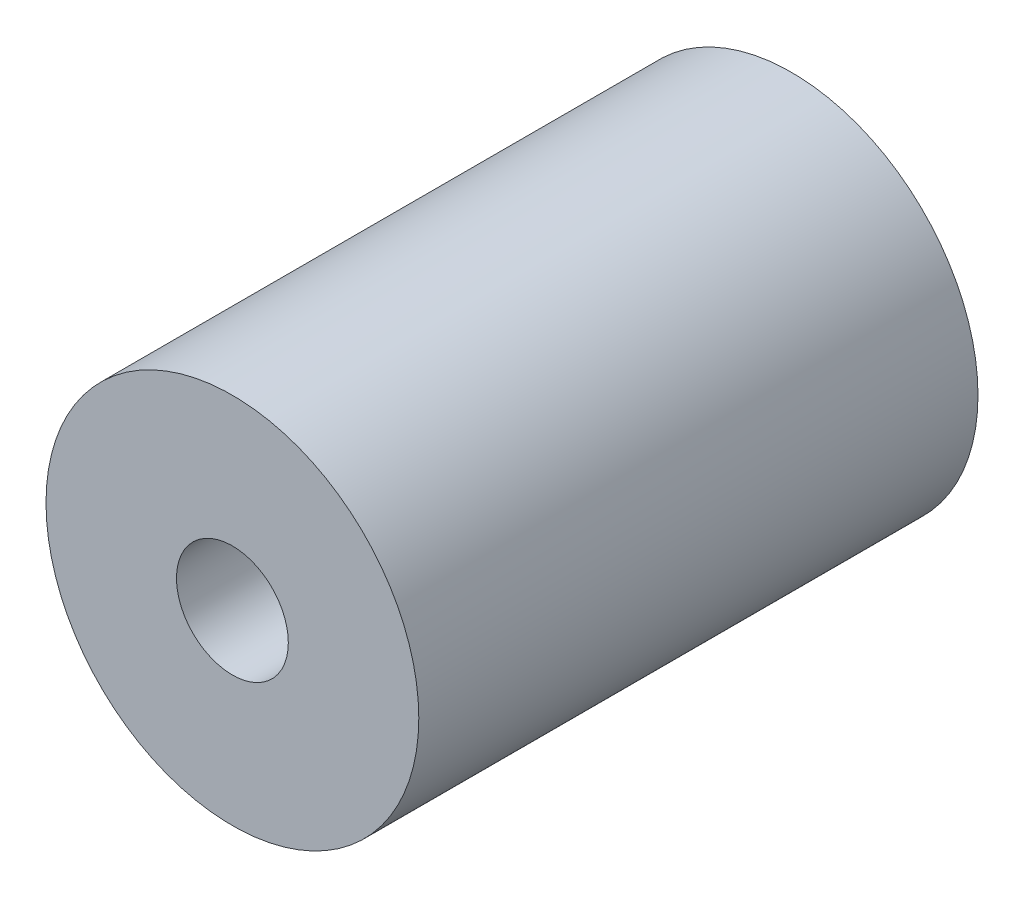
from build123d import *

# Parameters (mm, degrees)
SKETCH1_R           = 5
BOSS_EXTRUDE1_DEPTH = 15
SKETCH2_R           = 1.5
CUT_EXTRUDE1_DEPTH  = 20


with BuildPart() as part:
    # Sketch1 → Boss-Extrude1 (new body)
    with BuildSketch(Plane.XY):
        Circle(SKETCH1_R)
    extrude(amount=BOSS_EXTRUDE1_DEPTH)

    # Sketch2 → Cut-Extrude1 (cut)
    with BuildSketch(Plane.XY.offset(15)):
        Circle(SKETCH2_R)
    extrude(amount=-CUT_EXTRUDE1_DEPTH, mode=Mode.SUBTRACT)


solid = part.part
